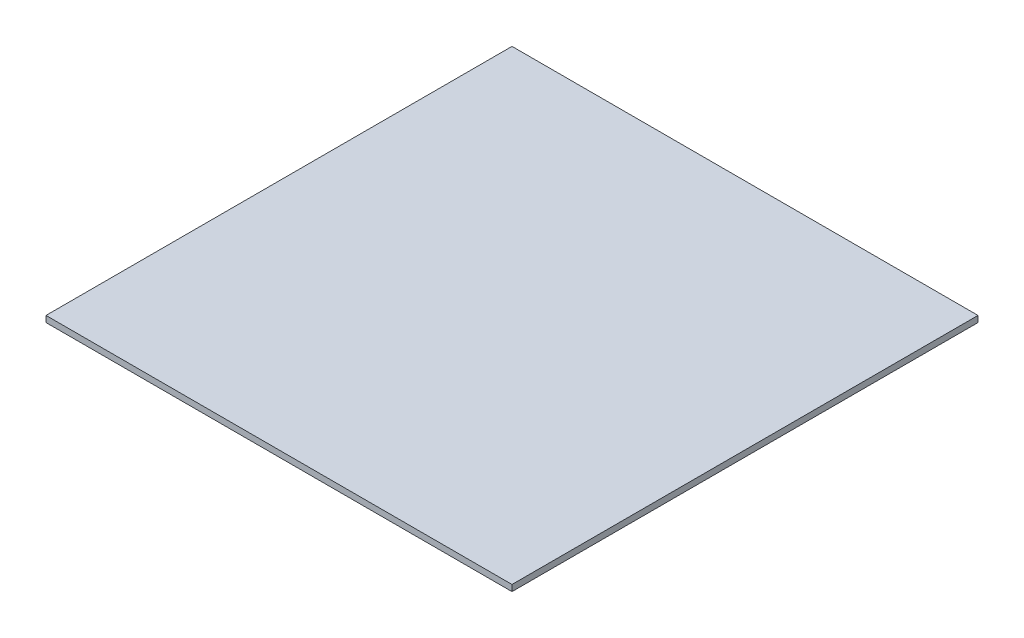
from build123d import *

# Parameters (mm, degrees)
ESQUISSE1_W        = 150
ESQUISSE1_H        = 150
BOSS_EXTRU_1_DEPTH = 2


with BuildPart() as part:
    # Esquisse1 → Boss.-Extru.1 (new body)
    with BuildSketch(Plane(origin=(0, 0, 0), x_dir=(1, 0, 0), z_dir=(0, 1, 0))):
        Rectangle(ESQUISSE1_W, ESQUISSE1_H)
    extrude(amount=BOSS_EXTRU_1_DEPTH)


solid = part.part
